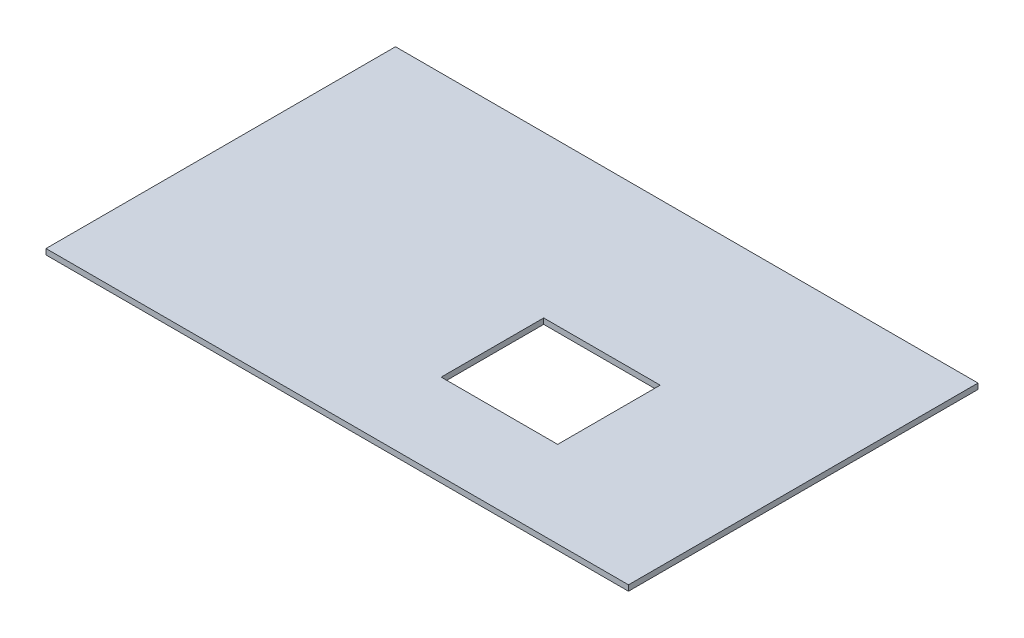
from build123d import *

# Parameters (mm, degrees)
SKETCH1_W               = 125
SKETCH1_H               = 75
SKETCH1_W_2             = 22
SKETCH1_H_2             = 22
BOSS_EXTRUDE1_DEPTH     = 1.2
SKETCH2_W               = 3
SKETCH2_H               = 22
CUT_EXTRUDE1_DEPTH      = 1
CUT_EXTRUDE1_DEPTH_BACK = 2.2


with BuildPart() as part:
    # Sketch1 → Boss-Extrude1 (new body)
    with BuildSketch(Plane(origin=(0, 0, 0), x_dir=(1, 0, 0), z_dir=(0, 1, 0))):
        Rectangle(SKETCH1_W, SKETCH1_H)
        with Locations((14.8, -8)):
            Rectangle(SKETCH1_W_2, SKETCH1_H_2, mode=Mode.SUBTRACT)
    extrude(amount=BOSS_EXTRUDE1_DEPTH)

    # Sketch2 → Cut-Extrude1 (cut, two sides)
    with BuildSketch(Plane(origin=(0, 1.2, 0), x_dir=(1, 0, 0), z_dir=(0, 1, 0))) as cut_extrude1_sk:
        with Locations((27.3, -8)):
            Rectangle(SKETCH2_W, SKETCH2_H)
    extrude(amount=CUT_EXTRUDE1_DEPTH, mode=Mode.SUBTRACT)
    extrude(cut_extrude1_sk.sketch, amount=-CUT_EXTRUDE1_DEPTH_BACK, mode=Mode.SUBTRACT)


solid = part.part
